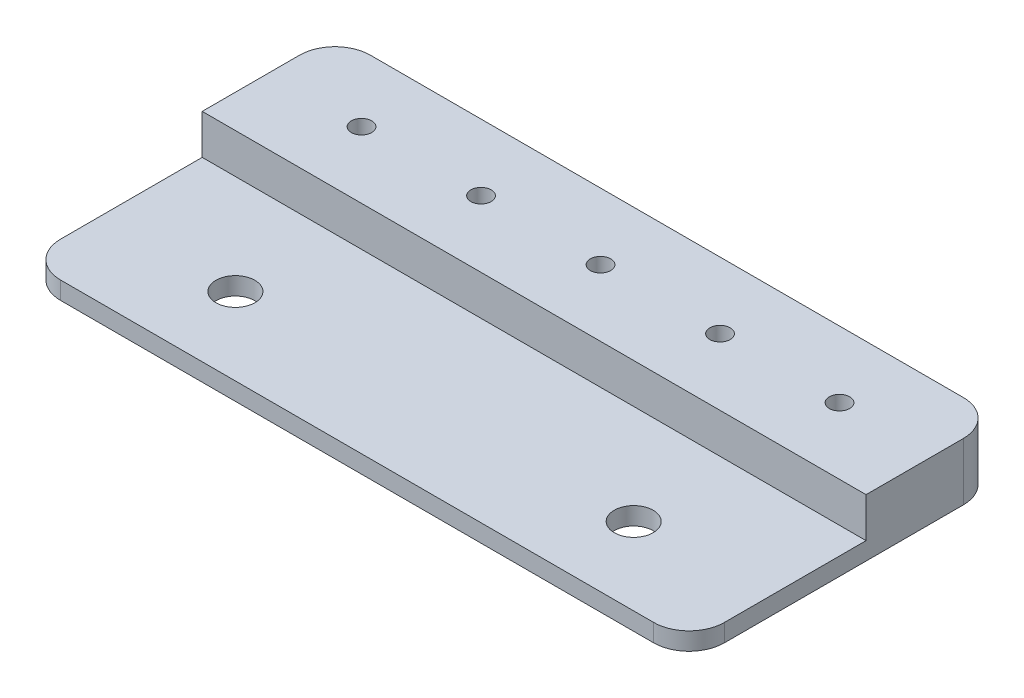
from build123d import *

# Parameters (mm, degrees)
SKETCH1_R           = 4.4
BOSS_EXTRUDE1_DEPTH = 4
BOSS_EXTRUDE2_DEPTH = 9
SKETCH3_R           = 2.3
CUT_EXTRUDE1_DEPTH  = 13


with BuildPart() as part:
    # Sketch1 → Boss-Extrude1 (new body)
    with BuildSketch(Plane(origin=(0, 0, 0), x_dir=(1, 0, 0), z_dir=(0, 1, 0))):
        with BuildLine():
            Line((-67, 35), (67, 35))
            ThreePointArc((67, 35), (72.656854249, 32.656854249), (75, 27))
            Line((75, 27), (75, -27))
            ThreePointArc((75, -27), (72.656854249, -32.656854249), (67, -35))
            Line((67, -35), (-67, -35))
            ThreePointArc((-67, -35), (-72.656854249, -32.656854249), (-75, -27))
            Line((-75, -27), (-75, 27))
            ThreePointArc((-75, 27), (-72.656854249, 32.656854249), (-67, 35))
        make_face()
        with Locations((-45, -17.5)):
            Circle(SKETCH1_R, mode=Mode.SUBTRACT)
        with Locations((45, -17.5)):
            Circle(SKETCH1_R, mode=Mode.SUBTRACT)
    extrude(amount=-BOSS_EXTRUDE1_DEPTH)

    # Sketch2 → Boss-Extrude2 (add)
    with BuildSketch(Plane(origin=(0, 0, 0), x_dir=(1, 0, 0), z_dir=(0, 1, 0))):
        with BuildLine():
            Line((-75, 5), (75, 5))
            Line((75, 5), (75, 27))
            ThreePointArc((75, 27), (72.656854249, 32.656854249), (67, 35))
            Line((67, 35), (-67, 35))
            ThreePointArc((-67, 35), (-72.656854249, 32.656854249), (-75, 27))
            Line((-75, 27), (-75, 5))
        make_face()
    extrude(amount=BOSS_EXTRUDE2_DEPTH)

    # Sketch3 → Cut-Extrude1 (cut)
    with BuildSketch(Plane(origin=(0, 9, 0), x_dir=(1, 0, 0), z_dir=(0, 1, 0))):
        with Locations((-54, 20)):
            Circle(SKETCH3_R)
        with Locations((-27, 20)):
            Circle(SKETCH3_R)
        with Locations((0, 20)):
            Circle(SKETCH3_R)
        with Locations((27, 20)):
            Circle(SKETCH3_R)
        with Locations((54, 20)):
            Circle(SKETCH3_R)
    extrude(amount=-CUT_EXTRUDE1_DEPTH, mode=Mode.SUBTRACT)


solid = part.part
